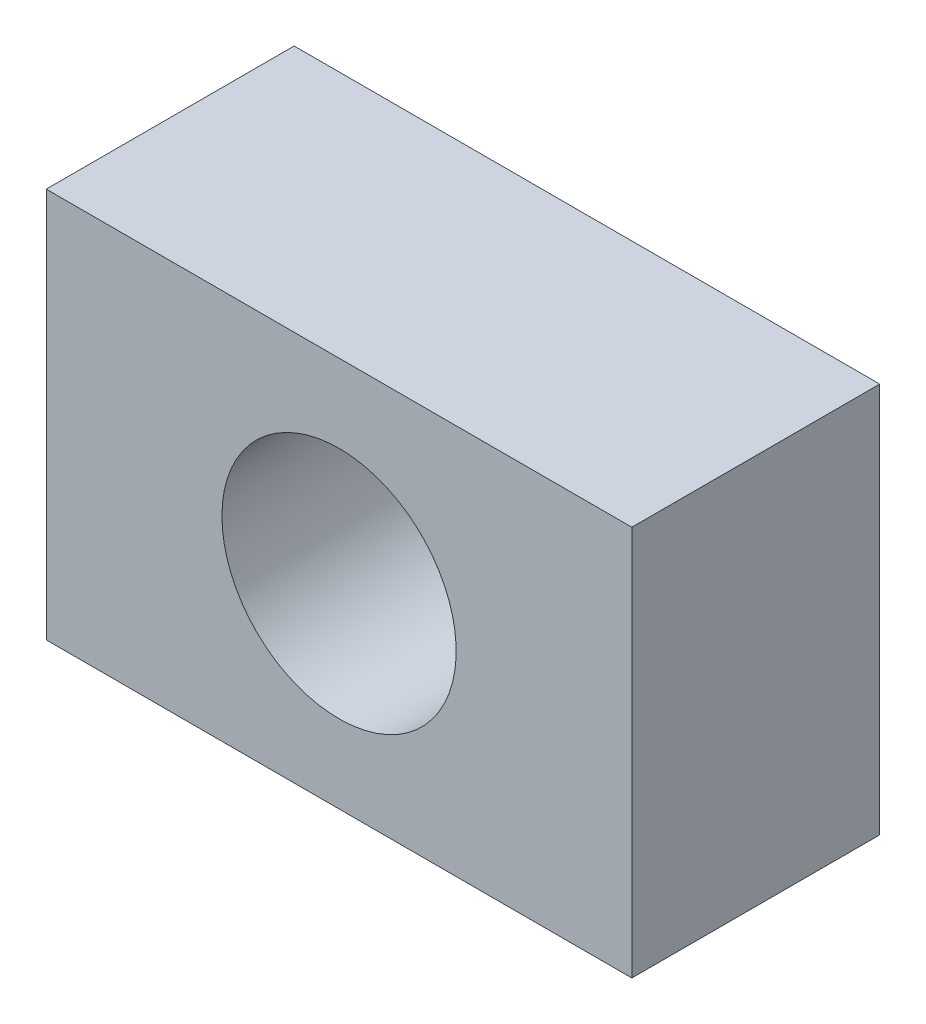
from build123d import *

# Parameters (mm, degrees)
SKETCH1_W           = 15
SKETCH1_H           = 10
BOSS_EXTRUDE1_DEPTH = 6.35
SKETCH2_R           = 3
CUT_EXTRUDE1_DEPTH  = 7.35


with BuildPart() as part:
    # Sketch1 → Boss-Extrude1 (new body)
    with BuildSketch(Plane.XY):
        Rectangle(SKETCH1_W, SKETCH1_H)
    extrude(amount=BOSS_EXTRUDE1_DEPTH)

    # Sketch2 → Cut-Extrude1 (cut, through all)
    with BuildSketch(Plane(origin=(0, 0, 0), x_dir=(-1, 0, 0), z_dir=(0, 0, -1))):
        Circle(SKETCH2_R)
    extrude(amount=-CUT_EXTRUDE1_DEPTH, mode=Mode.SUBTRACT)


solid = part.part
